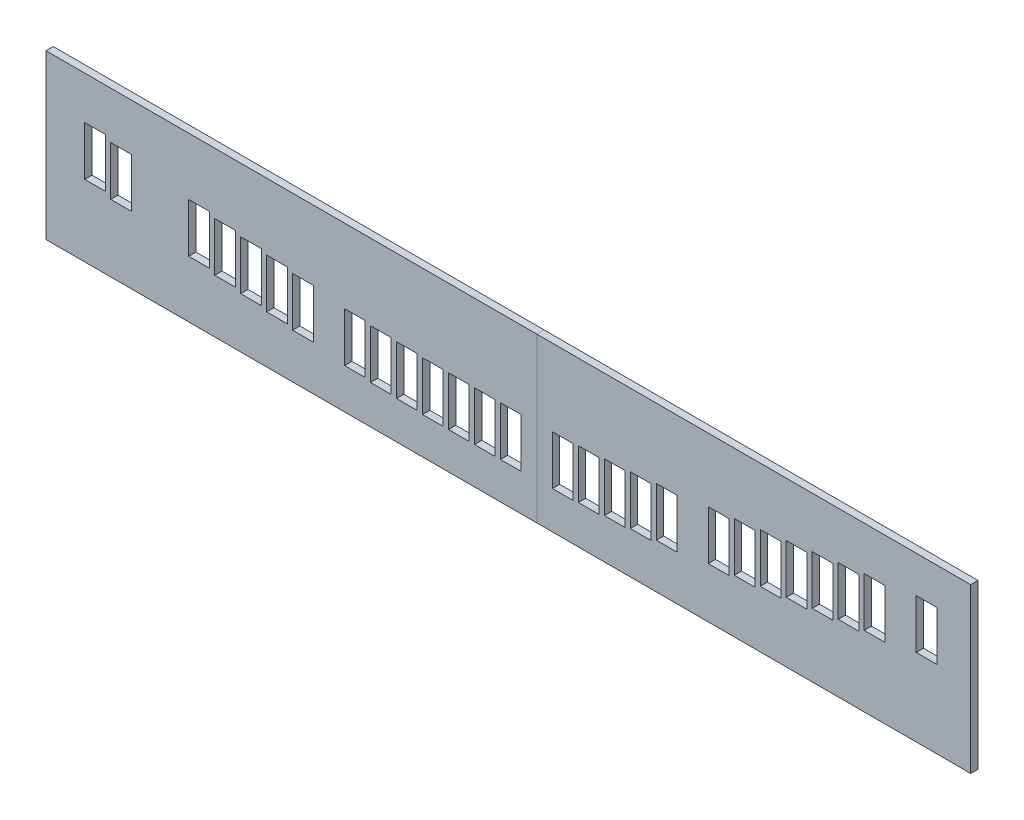
from build123d import *

# Parameters (mm, degrees)
SKETCH2_W           = 1647.9
SKETCH2_H           = 284.681734848
SKETCH2_W_2         = 36
SKETCH2_H_2         = 85.677465121
BOSS_EXTRUDE1_DEPTH = 12.7
SKETCH3_W           = 19.05
SKETCH3_H           = 284.681734848
CUT_EXTRUDE1_DEPTH  = 13.7
SKETCH4_W           = 36
SKETCH4_H           = 50.330449982
SKETCH4_H_2         = 35.349550018
CUT_EXTRUDE2_DEPTH  = 13.7


with BuildPart() as part:
    # Sketch2 → Boss-Extrude1 (new body)
    with BuildSketch(Plane.XY):
        with Locations((842.999943303, 176.189566708)):
            Rectangle(SKETCH2_W, SKETCH2_H)
        with Locations((1571.01994314, 211.688120447)):
            Rectangle(SKETCH2_W_2, SKETCH2_H_2, mode=Mode.SUBTRACT)
        with Locations((1480.459247559, 199.688120447)):
            Rectangle(SKETCH2_W_2, SKETCH2_H_2, mode=Mode.SUBTRACT)
        with Locations((1435.229386921, 193.688120447)):
            Rectangle(SKETCH2_W_2, SKETCH2_H_2, mode=Mode.SUBTRACT)
        with Locations((1390.000695887, 187.688120447)):
            Rectangle(SKETCH2_W_2, SKETCH2_H_2, mode=Mode.SUBTRACT)
        with Locations((1344.768303255, 181.688120447)):
            Rectangle(SKETCH2_W_2, SKETCH2_H_2, mode=Mode.SUBTRACT)
        with Locations((1299.538396377, 175.688120447)):
            Rectangle(SKETCH2_W_2, SKETCH2_H_2, mode=Mode.SUBTRACT)
        with Locations((1254.306140471, 169.688120446)):
            Rectangle(SKETCH2_W_2, SKETCH2_H_2, mode=Mode.SUBTRACT)
        with Locations((1209.07770281, 164.688120446)):
            Rectangle(SKETCH2_W_2, SKETCH2_H_2, mode=Mode.SUBTRACT)
        with Locations((1118.618578512, 154.688120446)):
            Rectangle(SKETCH2_W_2, SKETCH2_H_2, mode=Mode.SUBTRACT)
        with Locations((1073.383844827, 149.688120446)):
            Rectangle(SKETCH2_W_2, SKETCH2_H_2, mode=Mode.SUBTRACT)
        with Locations((1028.155686863, 146.688120446)):
            Rectangle(SKETCH2_W_2, SKETCH2_H_2, mode=Mode.SUBTRACT)
        with Locations((982.9239215, 143.688120446)):
            Rectangle(SKETCH2_W_2, SKETCH2_H_2, mode=Mode.SUBTRACT)
        with Locations((937.694704034, 142.188120446)):
            Rectangle(SKETCH2_W_2, SKETCH2_H_2, mode=Mode.SUBTRACT)
        with Locations((847.230489128, 140.688120446)):
            Rectangle(SKETCH2_W_2, SKETCH2_H_2, mode=Mode.SUBTRACT)
        with Locations((801.999943303, 140.688120446)):
            Rectangle(SKETCH2_W_2, SKETCH2_H_2, mode=Mode.SUBTRACT)
        with Locations((756.774236257, 140.688120446)):
            Rectangle(SKETCH2_W_2, SKETCH2_H_2, mode=Mode.SUBTRACT)
        with Locations((711.541406556, 140.688120446)):
            Rectangle(SKETCH2_W_2, SKETCH2_H_2, mode=Mode.SUBTRACT)
        with Locations((666.310021351, 142.188120446)):
            Rectangle(SKETCH2_W_2, SKETCH2_H_2, mode=Mode.SUBTRACT)
        with Locations((621.080803885, 143.688120446)):
            Rectangle(SKETCH2_W_2, SKETCH2_H_2, mode=Mode.SUBTRACT)
        with Locations((575.849038522, 146.688120446)):
            Rectangle(SKETCH2_W_2, SKETCH2_H_2, mode=Mode.SUBTRACT)
        with Locations((485.386146872, 154.688120446)):
            Rectangle(SKETCH2_W_2, SKETCH2_H_2, mode=Mode.SUBTRACT)
        with Locations((304.466329007, 175.688120447)):
            Rectangle(SKETCH2_W_2, SKETCH2_H_2, mode=Mode.SUBTRACT)
        with Locations((440.15644292, 159.688120446)):
            Rectangle(SKETCH2_W_2, SKETCH2_H_2, mode=Mode.SUBTRACT)
        with Locations((394.927022575, 164.688120446)):
            Rectangle(SKETCH2_W_2, SKETCH2_H_2, mode=Mode.SUBTRACT)
        with Locations((349.698584914, 169.688120446)):
            Rectangle(SKETCH2_W_2, SKETCH2_H_2, mode=Mode.SUBTRACT)
        with Locations((168.775338464, 193.688120447)):
            Rectangle(SKETCH2_W_2, SKETCH2_H_2, mode=Mode.SUBTRACT)
    extrude(amount=BOSS_EXTRUDE1_DEPTH)

    # Sketch3 → Cut-Extrude1 (cut, through all)
    with BuildSketch(Plane.XY.offset(12.7)):
        with Locations((1657.424943303, 176.189566708)):
            Rectangle(SKETCH3_W, SKETCH3_H)
        with Locations((28.574943303, 176.189566708)):
            Rectangle(SKETCH3_W, SKETCH3_H)
    extrude(amount=-CUT_EXTRUDE1_DEPTH, mode=Mode.SUBTRACT)

    # Sketch4 → Cut-Extrude2 (cut, through all)
    with BuildSketch(Plane.XY.offset(12.7)):
        with Locations((123.545338464, 218.853345438)):
            Rectangle(SKETCH4_W, SKETCH4_H)
        with Locations((123.545338464, 176.013345438)):
            Rectangle(SKETCH4_W, SKETCH4_H_2)
    extrude(amount=-CUT_EXTRUDE2_DEPTH, mode=Mode.SUBTRACT)


with BuildPart() as body_2:
    # Split1: the piece on the far side of the plane
    add(part.part)
    split(bisect_by=Plane(origin=(892.462596581, 0, 0), x_dir=(0, 0, -1), z_dir=(-1, 0, 0)), keep=Keep.BOTTOM)


with BuildPart() as part_1:
    add(part.part)

    # Split1
    split(bisect_by=Plane(origin=(892.462596581, 0, 0), x_dir=(0, 0, -1), z_dir=(-1, 0, 0)), keep=Keep.TOP)


solid = Compound([body_2.part, part_1.part])
